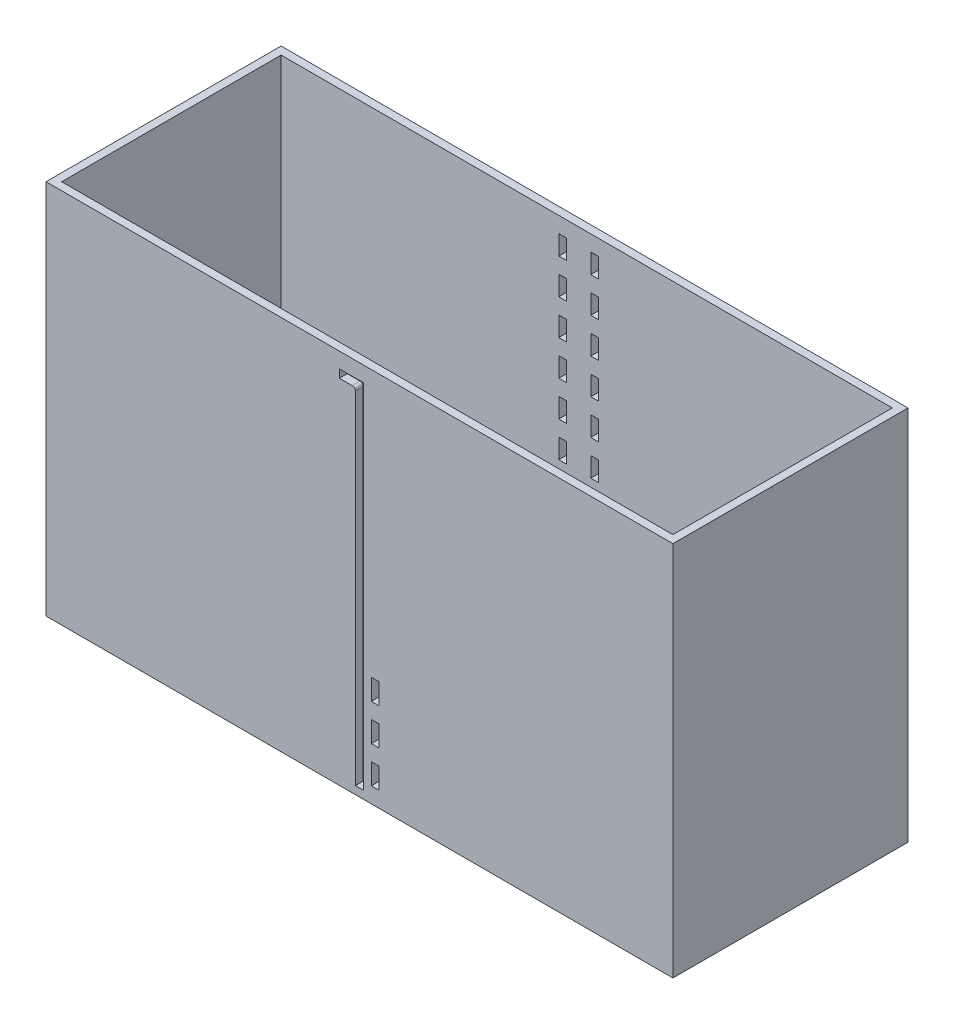
from build123d import *

# Parameters (mm, degrees)
SKETCH1_W           = 508
SKETCH1_H           = 190.5
BOSS_EXTRUDE1_DEPTH = 6.35
SKETCH2_W           = 508
SKETCH2_H           = 190.5
SKETCH2_W_2         = 495.3
SKETCH2_H_2         = 177.8
BOSS_EXTRUDE2_DEPTH = 298.45
SKETCH3_W           = 6.35
SKETCH3_H           = 16.933333333
SKETCH3_H_2         = 16.933333334
CUT_EXTRUDE1_DEPTH  = 12.7
SKETCH4_W           = 6.35
SKETCH4_H           = 15.875
CUT_EXTRUDE2_DEPTH  = 6.35


with BuildPart() as part:
    # Sketch1 → Boss-Extrude1 (new body)
    with BuildSketch(Plane(origin=(0, 0, 0), x_dir=(1, 0, 0), z_dir=(0, 1, 0))):
        Rectangle(SKETCH1_W, SKETCH1_H)
    extrude(amount=BOSS_EXTRUDE1_DEPTH)

    # Sketch2 → Boss-Extrude2 (add)
    with BuildSketch(Plane(origin=(0, 6.35, 0), x_dir=(1, 0, 0), z_dir=(0, 1, 0))):
        Rectangle(SKETCH2_W, SKETCH2_H)
        Rectangle(SKETCH2_W_2, SKETCH2_H_2, mode=Mode.SUBTRACT)
    extrude(amount=BOSS_EXTRUDE2_DEPTH)

    # Sketch3 → Cut-Extrude1 (cut)
    with BuildSketch(Plane.XY.offset(95.25)):
        with BuildLine():
            Line((-3.302, 283.21), (-3.302, 6.35))
            Line((-3.302, 6.35), (3.302, 6.35))
            Line((3.302, 6.35), (3.302, 292.354))
            Line((3.302, 292.354), (-16.256, 292.354))
            Line((-16.256, 292.354), (-16.256, 285.75))
            Line((-16.256, 285.75), (-5.842, 285.75))
            ThreePointArc((-5.842, 285.75), (-4.045948776, 285.006051224), (-3.302, 283.21))
        make_face()
        with Locations((12.827, 80.433333334)):
            Rectangle(SKETCH3_W, SKETCH3_H)
        with Locations((12.827, 50.8)):
            Rectangle(SKETCH3_W, SKETCH3_H_2)
        with Locations((12.827, 21.166666667)):
            Rectangle(SKETCH3_W, SKETCH3_H)
    extrude(amount=-CUT_EXTRUDE1_DEPTH, mode=Mode.SUBTRACT)

    # Sketch4 → Cut-Extrude2 (cut)
    with BuildSketch(Plane.XY.offset(-88.9)):
        with Locations((-19.431, 284.1625)):
            Rectangle(SKETCH4_W, SKETCH4_H)
        with Locations((-19.431, 255.5875)):
            Rectangle(SKETCH4_W, SKETCH4_H)
        with Locations((-19.431, 227.0125)):
            Rectangle(SKETCH4_W, SKETCH4_H)
        with Locations((-19.431, 198.4375)):
            Rectangle(SKETCH4_W, SKETCH4_H)
        with Locations((-19.431, 169.8625)):
            Rectangle(SKETCH4_W, SKETCH4_H)
        with Locations((-19.431, 141.2875)):
            Rectangle(SKETCH4_W, SKETCH4_H)
        with Locations((-19.431, 112.7125)):
            Rectangle(SKETCH4_W, SKETCH4_H)
        with Locations((-19.431, 84.1375)):
            Rectangle(SKETCH4_W, SKETCH4_H)
        with Locations((-19.431, 55.5625)):
            Rectangle(SKETCH4_W, SKETCH4_H)
        with Locations((-19.431, 26.9875)):
            Rectangle(SKETCH4_W, SKETCH4_H)
    cut_extrude2 = extrude(amount=-CUT_EXTRUDE2_DEPTH, mode=Mode.SUBTRACT)

    # Mirror1: Cut-Extrude2 across plane
    add(cut_extrude2.mirror(Plane.ZY.offset(6.477)), mode=Mode.SUBTRACT)


solid = part.part
